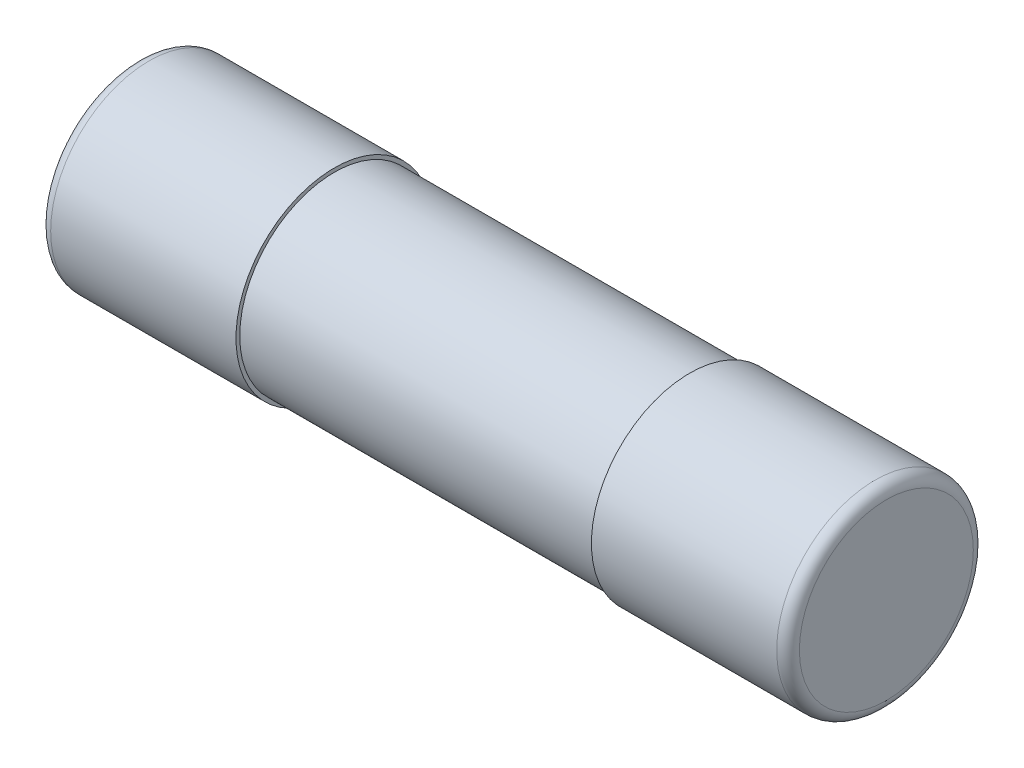
from build123d import *

# Parameters (mm, degrees)
ESQUISSE1_R           = 2.5
BOSS_EXTRU_1_DEPTH    = 4.7
ESQUISSE2_R           = 2.6
BOSS_EXTRU_2_DEPTH    = 5.2
CONG_1_R              = 0.3
CONG_1_OF_SYM_TRIE1_R = 0.3


with BuildPart() as part:
    # Esquisse1 → Boss.-Extru.1 (new body, symmetric)
    with BuildSketch(Plane(origin=(0, 0, 0), x_dir=(0, 0, -1), z_dir=(1, 0, 0))):
        Circle(ESQUISSE1_R)
    extrude(amount=BOSS_EXTRU_1_DEPTH, both=True)

    # Esquisse2 → Boss.-Extru.2 (add)
    with BuildSketch(Plane(origin=(4.7, 0, 0), x_dir=(0, 0, -1), z_dir=(1, 0, 0))):
        Circle(ESQUISSE2_R)
    boss_extru_2 = extrude(amount=BOSS_EXTRU_2_DEPTH)

    # Congé1
    cong_1_edges = [part.edges().sort_by_distance(p)[0] for p in [
        (9.9, 0, 2.6),
    ]]
    fillet(cong_1_edges, radius=CONG_1_R)

    # Symétrie1: Boss.-Extru.2 across plane
    add(boss_extru_2.mirror(Plane(origin=(0, 0, 0), x_dir=(0, 0, 1), z_dir=(1, 0, 0))))

    # Congé1 of Symétrie1
    cong_1_of_sym_trie1_edges = [part.edges().sort_by_distance(p)[0] for p in [
        (-9.9, 0, 2.6),
    ]]
    fillet(cong_1_of_sym_trie1_edges, radius=CONG_1_OF_SYM_TRIE1_R)


solid = part.part
